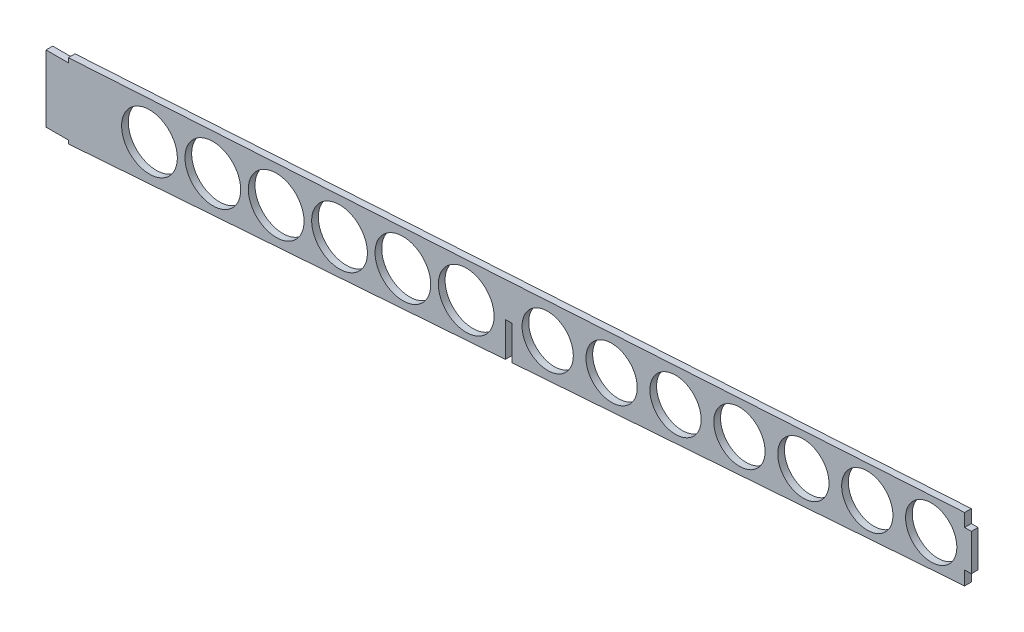
from build123d import *

# Parameters (mm, degrees)
BOSS_EXTRUDE1_DEPTH     = 3
SKETCH2_R               = 12.5
SKETCH2_R_2             = 11.5
SKETCH2_W               = 3
SKETCH2_H               = 15.519078079
CUT_EXTRUDE1_DEPTH      = 1
CUT_EXTRUDE1_DEPTH_BACK = 4
SKETCH3_W               = 3
SKETCH3_H               = 6
SKETCH3_H_2             = 7.329652721
CUT_EXTRUDE2_DEPTH      = 10


with BuildPart() as part:
    # Sketch1 → Boss-Extrude1 (new body)
    with BuildSketch(Plane.XY):
        Polygon((-415, 1.5), (-415, 31.5), (-405, 31.5), (-405, 33.5), (0, 58.019626957), (0, 29.519626957), (-405, 0), (-405, 1.5), align=None)
    extrude(amount=BOSS_EXTRUDE1_DEPTH)

    # Sketch2 → Cut-Extrude1 (cut, two sides)
    with BuildSketch(Plane.XY.offset(3)) as cut_extrude1_sk:
        with Locations((-368.587798604, 18.953006079)):
            Circle(SKETCH2_R)
        with Locations((-340.175597209, 20.867070597)):
            Circle(SKETCH2_R)
        with Locations((-311.763395813, 22.781135116)):
            Circle(SKETCH2_R)
        with Locations((-283.351194418, 24.695199634)):
            Circle(SKETCH2_R)
        with Locations((-254.938993022, 26.609264153)):
            Circle(SKETCH2_R)
        with Locations((-226.526791627, 28.523328671)):
            Circle(SKETCH2_R)
        with Locations((-190, 30.98405443)):
            Circle(SKETCH2_R_2)
        with Locations((-161.331258472, 32.915401465)):
            Circle(SKETCH2_R_2)
        with Locations((-132.662516945, 34.846748501)):
            Circle(SKETCH2_R_2)
        with Locations((-103.993775417, 36.778095537)):
            Circle(SKETCH2_R_2)
        with Locations((-75.325033889, 38.709442573)):
            Circle(SKETCH2_R_2)
        with Locations((-46.656292362, 40.640789609)):
            Circle(SKETCH2_R_2)
        with Locations((-17.987550834, 42.572136645)):
            Circle(SKETCH2_R_2)
        with Locations((-207.5, 22.045580728)):
            Rectangle(SKETCH2_W, SKETCH2_H)
    extrude(amount=CUT_EXTRUDE1_DEPTH, mode=Mode.SUBTRACT)
    extrude(cut_extrude1_sk.sketch, amount=-CUT_EXTRUDE1_DEPTH_BACK, mode=Mode.SUBTRACT)

    # Sketch3 → Cut-Extrude2 (cut)
    with BuildSketch(Plane.XY.offset(3)):
        with Locations((-1.5, 55.019626957)):
            Rectangle(SKETCH3_W, SKETCH3_H)
        with Locations((-1.5, 31.854800596)):
            Rectangle(SKETCH3_W, SKETCH3_H_2)
    extrude(amount=-CUT_EXTRUDE2_DEPTH, mode=Mode.SUBTRACT)


solid = part.part
